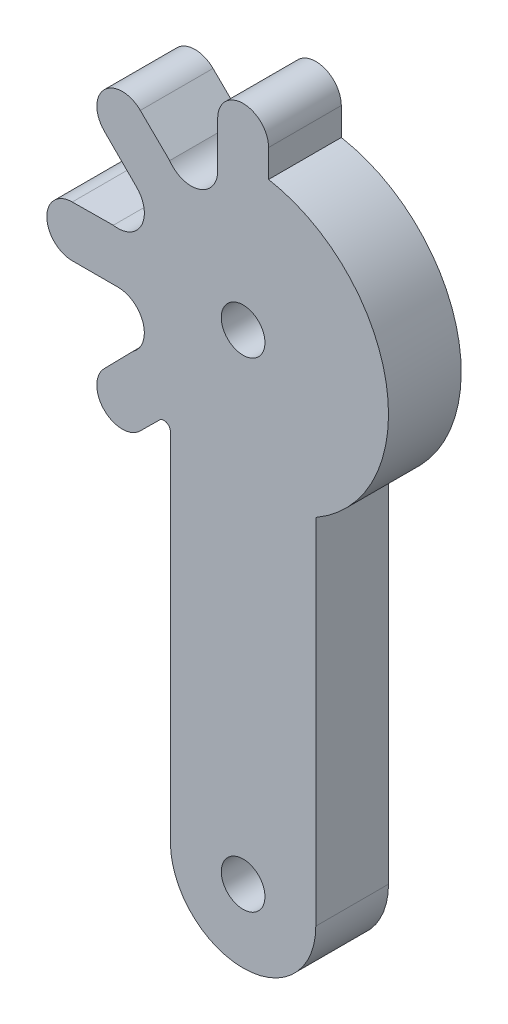
from build123d import *

# Parameters (mm, degrees)
SKETCH2_R           = 1.5
BOSS_EXTRUDE1_DEPTH = 5


with BuildPart() as part:
    # Sketch2 → Boss-Extrude1 (new body)
    with BuildSketch(Plane.XY):
        with BuildLine():
            Line((5, -8.660254038), (5, -33))
            ThreePointArc((5, -33), (0, -38), (-5, -33))
            Line((-5, -33), (-5, -8.542766751))
            ThreePointArc((-5, -8.542766751), (-5.270994803, -8.136429895), (-5.750270597, -8.230464661))
            Line((-5.750270597, -8.230464661), (-7.072992385, -9.544016527))
            ThreePointArc((-7.072992385, -9.544016527), (-9.548009447, -9.543873182), (-9.547579415, -7.068856154))
            Line((-9.547579415, -7.068856154), (-7.570062095, -5.051082723))
            ThreePointArc((-7.570062095, -5.051082723), (-6.875312951, -3.018601992), (-8.606609983, -1.747277927))
            Line((-8.606609983, -1.747277927), (-11.749999685, -1.747277927))
            ThreePointArc((-11.749999685, -1.747277927), (-13.499796954, 0.002924757), (-11.74959427, 1.752722026))
            Line((-11.74959427, 1.752722026), (-8.924497087, 1.781187396))
            ThreePointArc((-8.924497087, 1.781187396), (-6.996054349, 2.727106472), (-7.321304353, 4.850280211))
            Line((-7.321304353, 4.850280211), (-9.544016527, 7.072992385))
            ThreePointArc((-9.544016527, 7.072992385), (-9.543729855, 9.547866086), (-7.068856154, 9.547579415))
            Line((-7.068856154, 9.547579415), (-5.051082723, 7.570062095))
            ThreePointArc((-5.051082723, 7.570062095), (-3.018601992, 6.875312951), (-1.747277927, 8.606609983))
            Line((-1.747277927, 8.606609983), (-1.747277927, 11.749999685))
            ThreePointArc((-1.747277927, 11.749999685), (0.002924781, 13.499999673), (1.752722026, 11.74959427))
            Line((1.752722026, 11.74959427), (1.752722026, 9.845200125))
            ThreePointArc((1.752722026, 9.845200125), (9.849506187, 1.728359878), (5, -8.660254038))
        make_face()
        with Locations((0, -33)):
            Circle(SKETCH2_R, mode=Mode.SUBTRACT)
        Circle(SKETCH2_R, mode=Mode.SUBTRACT)
    extrude(amount=BOSS_EXTRUDE1_DEPTH)


solid = part.part
